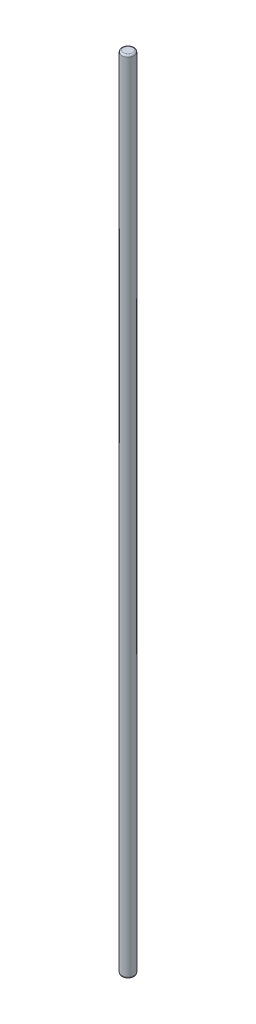
from build123d import *

# Parameters (mm, degrees)
SKETCH1_R           = 11.25
BOSS_EXTRUDE1_DEPTH = 1450
FILLET1_R           = 3


with BuildPart() as part:
    # Sketch1 → Boss-Extrude1 (new body)
    with BuildSketch(Plane(origin=(0, 0, 0), x_dir=(1, 0, 0), z_dir=(0, 1, 0))):
        Circle(SKETCH1_R)
    extrude(amount=BOSS_EXTRUDE1_DEPTH)

    # Fillet1
    fillet1_edges = [part.edges().sort_by_distance(p)[0] for p in [
        (-11.25, 0, 0),
        (-11.25, 1450, 0),
    ]]
    fillet(fillet1_edges, radius=FILLET1_R)


solid = part.part
